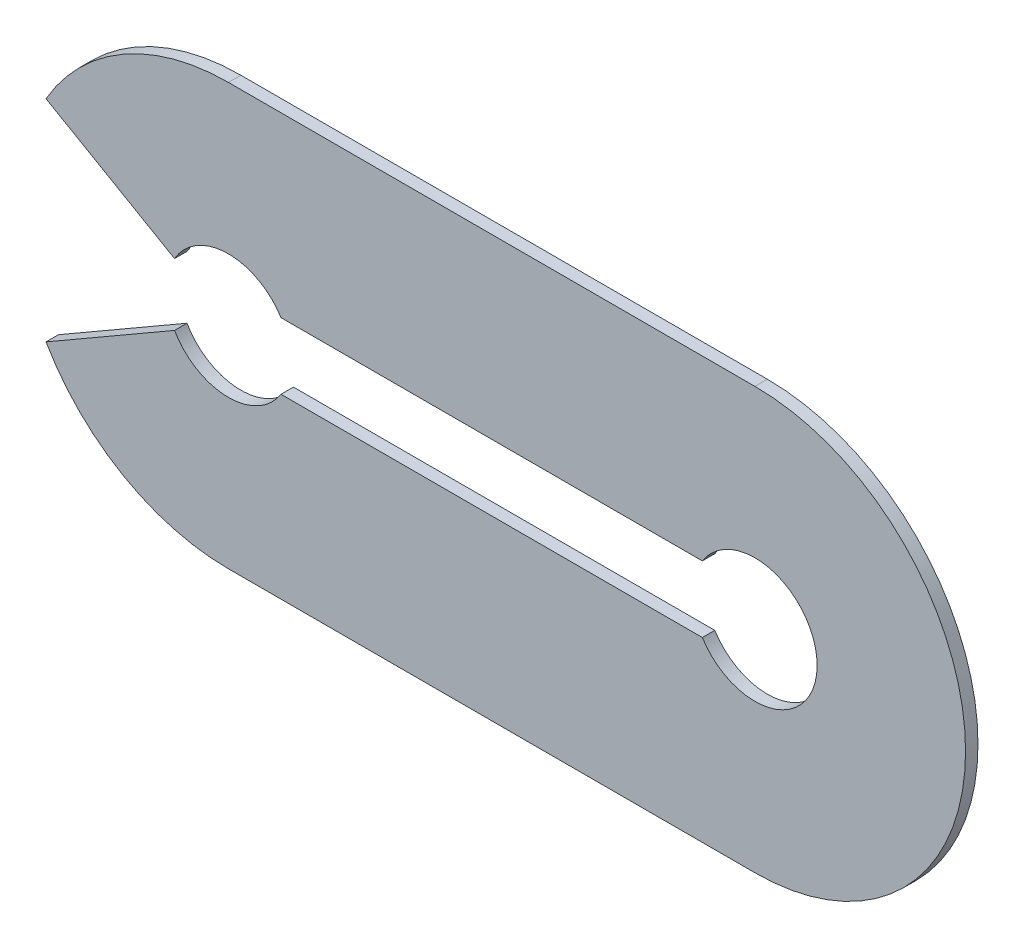
from build123d import *

# Parameters (mm, degrees)
EXTRUSION1_DEPTH = 0.3


with BuildPart() as part:
    # Esquisse1 → Extrusion1 (new body)
    with BuildSketch(Plane.XY):
        with BuildLine():
            Line((0, 5.08), (-12.7, 5.08))
            ThreePointArc((-12.7, 5.08), (-15.24, 4.399409051), (-17.099409051, 2.54))
            Line((-17.099409051, 2.54), (-13.999038106, 0.75))
            ThreePointArc((-13.999038106, 0.75), (-12.729201257, 1.499715735), (-11.431142246, 0.8))
            Line((-11.431142246, 0.8), (-1.268857754, 0.8))
            ThreePointArc((-1.268857754, 0.8), (1.5, 0), (-1.268857754, -0.8))
            Line((-1.268857754, -0.8), (-11.431142246, -0.8))
            ThreePointArc((-11.431142246, -0.8), (-12.729201257, -1.499715735), (-13.999038106, -0.75))
            Line((-13.999038106, -0.75), (-17.099409051, -2.54))
            ThreePointArc((-17.099409051, -2.54), (-15.24, -4.399409051), (-12.7, -5.08))
            Line((-12.7, -5.08), (0, -5.08))
            ThreePointArc((0, -5.08), (5.08, 0), (0, 5.08))
        make_face()
    extrude(amount=-EXTRUSION1_DEPTH)


solid = part.part
